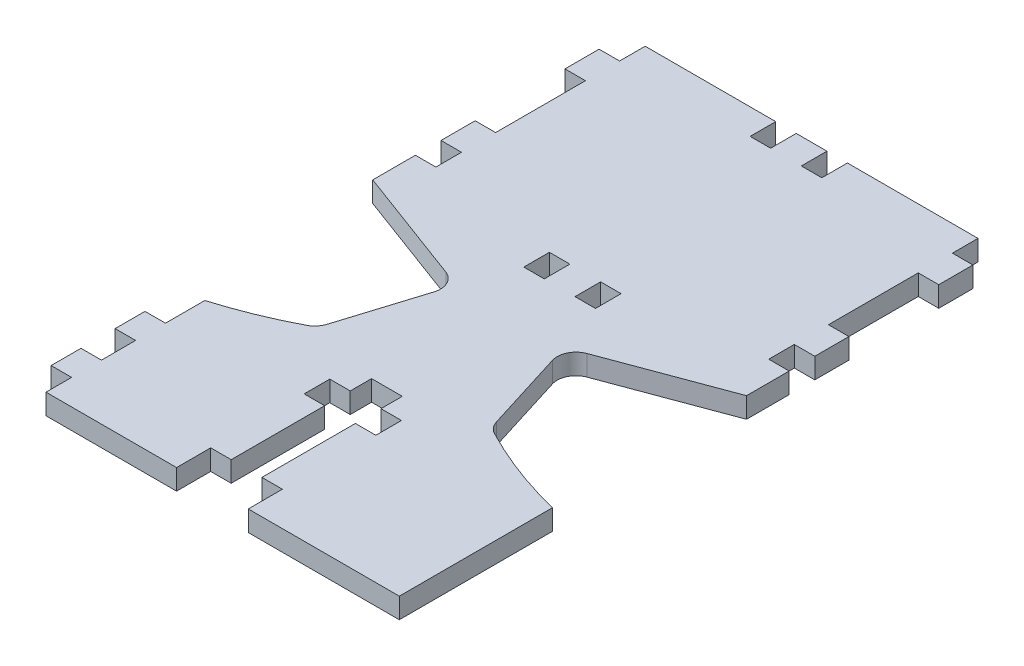
from build123d import *

# Parameters (mm, degrees)
SKETCH1_W           = 6.096
SKETCH1_H           = 7.62
BOSS_EXTRUDE1_DEPTH = 3.048


with BuildPart() as part:
    # Sketch1 → Boss-Extrude1 (new, symmetric)
    with BuildSketch(Plane(origin=(0, 0, 0), x_dir=(1, 0, 0), z_dir=(0, 1, 0))):
        with BuildLine():
            Line((-49.53, 45.72), (-10.668, 45.72))
            Line((-10.668, 45.72), (-10.668, 38.1))
            Line((-10.668, 38.1), (-4.572, 38.1))
            Line((-4.572, 38.1), (-4.572, 45.72))
            Line((-4.572, 45.72), (4.572, 45.72))
            Line((4.572, 45.72), (4.572, 38.1))
            Line((4.572, 38.1), (10.668, 38.1))
            Line((10.668, 38.1), (10.668, 45.72))
            Line((10.668, 45.72), (49.53, 45.72))
            Line((49.53, 45.72), (49.53, 38.1))
            Line((49.53, 38.1), (55.626, 38.1))
            Line((55.626, 38.1), (55.626, 27.94))
            Line((55.626, 27.94), (49.53, 27.94))
            Line((49.53, 27.94), (49.53, 1.208143374))
            Line((49.53, 1.208143374), (55.626, 1.208143374))
            Line((55.626, 1.208143374), (55.626, -8.951856626))
            Line((55.626, -8.951856626), (49.53, -8.951856626))
            Line((49.53, -8.951856626), (49.53, -16.571856626))
            Line((49.53, -16.571856626), (55.626, -16.571856626))
            Line((55.626, -16.571856626), (55.626, -29.271856626))
            Line((55.626, -29.271856626), (21.019827136, -42.136821893))
            ThreePointArc((21.019827136, -42.136821893), (17.95098831, -44.911778638), (17.631953735, -49.036869377))
            Line((17.631953735, -49.036869377), (25.187729856, -73.287029113))
            ThreePointArc((25.187729856, -73.287029113), (26.234780075, -75.207903536), (27.939063878, -76.579577488))
            ThreePointArc((27.939063878, -76.579577488), (41.468907088, -82.632484358), (55.626, -87.022365809))
            Line((55.626, -87.022365809), (55.626, -132.617292876))
            Line((55.626, -132.617292876), (10.668, -132.617292876))
            Line((10.668, -132.617292876), (10.668, -122.457292876))
            Line((10.668, -122.457292876), (4.572, -122.457292876))
            Line((4.572, -122.457292876), (4.572, -94.642365809))
            Line((4.572, -94.642365809), (10.668, -94.642365809))
            Line((10.668, -94.642365809), (10.668, -87.022365809))
            Line((10.668, -87.022365809), (4.572, -87.022365809))
            Line((4.572, -87.022365809), (4.572, -80.672365809))
            Line((4.572, -80.672365809), (-4.572, -80.672365809))
            Line((-4.572, -80.672365809), (-4.572, -87.022365809))
            Line((-4.572, -87.022365809), (-10.668, -87.022365809))
            Line((-10.668, -87.022365809), (-10.668, -94.642365809))
            Line((-10.668, -94.642365809), (-4.572, -94.642365809))
            Line((-4.572, -94.642365809), (-4.572, -122.457292876))
            Line((-4.572, -122.457292876), (-10.668, -122.457292876))
            Line((-10.668, -122.457292876), (-10.668, -132.617292876))
            Line((-10.668, -132.617292876), (-49.53, -132.617292876))
            Line((-49.53, -132.617292876), (-49.53, -124.997292876))
            Line((-49.53, -124.997292876), (-55.626, -124.997292876))
            Line((-55.626, -124.997292876), (-55.626, -116.107292876))
            Line((-55.626, -116.107292876), (-49.53, -116.107292876))
            Line((-49.53, -116.107292876), (-49.53, -105.947292876))
            Line((-49.53, -105.947292876), (-55.626, -105.947292876))
            Line((-55.626, -105.947292876), (-55.626, -97.057292876))
            Line((-55.626, -97.057292876), (-49.53, -97.057292876))
            Line((-49.53, -97.057292876), (-49.53, -85.359826344))
            ThreePointArc((-49.53, -85.359826344), (-38.527111219, -81.479756652), (-27.939063878, -76.579577488))
            ThreePointArc((-27.939063878, -76.579577488), (-26.234780075, -75.207903536), (-25.187729856, -73.287029113))
            Line((-25.187729856, -73.287029113), (-17.631953735, -49.036869377))
            ThreePointArc((-17.631953735, -49.036869377), (-17.95098831, -44.911778638), (-21.019827136, -42.136821893))
            Line((-21.019827136, -42.136821893), (-55.626, -29.271856626))
            Line((-55.626, -29.271856626), (-55.626, -16.571856626))
            Line((-55.626, -16.571856626), (-49.53, -16.571856626))
            Line((-49.53, -16.571856626), (-49.53, -8.951856626))
            Line((-49.53, -8.951856626), (-55.626, -8.951856626))
            Line((-55.626, -8.951856626), (-55.626, 1.208143374))
            Line((-55.626, 1.208143374), (-49.53, 1.208143374))
            Line((-49.53, 1.208143374), (-49.53, 27.94))
            Line((-49.53, 27.94), (-55.626, 27.94))
            Line((-55.626, 27.94), (-55.626, 38.1))
            Line((-55.626, 38.1), (-49.53, 38.1))
            Line((-49.53, 38.1), (-49.53, 45.72))
        make_face()
        with Locations((7.62, -25.461856626)):
            Rectangle(SKETCH1_W, SKETCH1_H, mode=Mode.SUBTRACT)
        with Locations((-7.62, -25.461856626)):
            Rectangle(SKETCH1_W, SKETCH1_H, mode=Mode.SUBTRACT)
    extrude(amount=BOSS_EXTRUDE1_DEPTH, both=True)


solid = part.part
